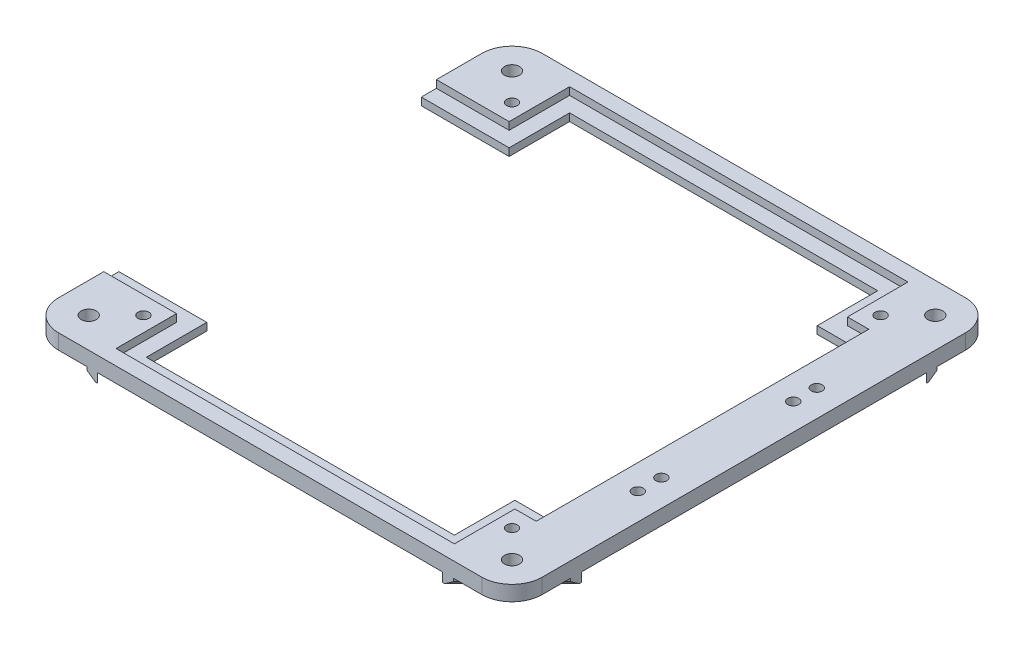
from build123d import *

# Parameters (mm, degrees)
BOSS_EXTRUDE2_DEPTH = 6.35
SKETCH2_R           = 3.175
CUT_EXTRUDE1_DEPTH  = 7.35
SKETCH7_R           = 2.286
CUT_EXTRUDE3_DEPTH  = 12.7
SKETCH8_R           = 2.286
CUT_EXTRUDE4_DEPTH  = 7.35
SKETCH9_W           = 129.404437756
SKETCH9_H           = 25.4
CUT_EXTRUDE5_DEPTH  = 7.35
CUT_EXTRUDE6_DEPTH  = 3.175
BOSS_EXTRUDE3_DEPTH = 3.81
CHAMFER1_SIZE       = 2.54


with BuildPart() as part:
    # Sketch1 → Boss-Extrude2 (new body)
    with BuildSketch(Plane(origin=(0, 0, 0), x_dir=(1, 0, 0), z_dir=(0, 1, 0))):
        with BuildLine():
            Line((0, 0), (0, 25.4))
            ThreePointArc((0, 25.4), (3.719743879, 34.380256121), (12.7, 38.1))
            Line((12.7, 38.1), (190.5, 38.1))
            ThreePointArc((190.5, 38.1), (199.480256121, 34.380256121), (203.2, 25.4))
            Line((203.2, 25.4), (203.2, -152.4))
            ThreePointArc((203.2, -152.4), (199.480256121, -161.380256121), (190.5, -165.1))
            Line((190.5, -165.1), (12.7, -165.1))
            ThreePointArc((12.7, -165.1), (3.719743879, -161.380256121), (0, -152.4))
            Line((0, -152.4), (0, -127))
            Line((0, -127), (181.61, -127))
            Line((181.61, -127), (181.61, 0))
            Line((181.61, 0), (0, 0))
        make_face()
    extrude(amount=BOSS_EXTRUDE2_DEPTH)

    # Sketch2 → Cut-Extrude1 (cut, through all)
    with BuildSketch(Plane(origin=(0, 6.35, 0), x_dir=(1, 0, 0), z_dir=(0, 1, 0))):
        with Locations((12.7, 25.4)):
            Circle(SKETCH2_R)
        with Locations((190.5, 25.4)):
            Circle(SKETCH2_R)
        with Locations((190.5, -152.4)):
            Circle(SKETCH2_R)
        with Locations((12.7, -152.4)):
            Circle(SKETCH2_R)
    extrude(amount=-CUT_EXTRUDE1_DEPTH, mode=Mode.SUBTRACT)

    # Sketch7 → Cut-Extrude3 (cut)
    with BuildSketch(Plane(origin=(0, 6.35, 0), x_dir=(1, 0, 0), z_dir=(0, 1, 0))):
        with Locations((192.024, -101.092)):
            Circle(SKETCH7_R)
        with Locations((192.024, -91.186)):
            Circle(SKETCH7_R)
        with Locations((192.024, -35.814)):
            Circle(SKETCH7_R)
        with Locations((192.024, -25.908)):
            Circle(SKETCH7_R)
    extrude(amount=-CUT_EXTRUDE3_DEPTH, mode=Mode.SUBTRACT)

    # Sketch8 → Cut-Extrude4 (cut, through all)
    with BuildSketch(Plane(origin=(0, 0, 0), x_dir=(-1, 0, 0), z_dir=(0, -1, 0))):
        with Locations((-24.197781122, 13.902218878)):
            Circle(SKETCH8_R)
        with Locations((-24.197781122, -140.902218878)):
            Circle(SKETCH8_R)
        with Locations((-179.002218878, -140.902218878)):
            Circle(SKETCH8_R)
        with Locations((-179.002218878, 13.902218878)):
            Circle(SKETCH8_R)
    extrude(amount=-CUT_EXTRUDE4_DEPTH, mode=Mode.SUBTRACT)

    # Sketch9 → Cut-Extrude5 (cut, through all)
    with BuildSketch(Plane(origin=(0, 6.35, 0), x_dir=(1, 0, 0), z_dir=(0, 1, 0))):
        with Locations((101.6, 12.7)):
            Rectangle(SKETCH9_W, SKETCH9_H)
        with Locations((101.6, -139.7)):
            Rectangle(SKETCH9_W, SKETCH9_H)
    extrude(amount=-CUT_EXTRUDE5_DEPTH, mode=Mode.SUBTRACT)

    # Sketch10 → Cut-Extrude6 (cut)
    with BuildSketch(Plane(origin=(0, 6.35, 0), x_dir=(1, 0, 0), z_dir=(0, 1, 0))):
        Polygon((0, 6.35), (30.547781122, 6.35), (30.547781122, 31.75), (172.652218878, 31.75), (172.652218878, 6.35), (181.61, 6.35), (181.61, 0), (166.302218878, 0), (166.302218878, 25.4), (36.897781122, 25.4), (36.897781122, 0), (0, 0), align=None)
        Polygon((0, -127), (0, -133.35), (30.547781122, -133.35), (30.547781122, -158.75), (172.652218878, -158.75), (172.652218878, -133.35), (181.61, -133.35), (181.61, -127), (166.302218878, -127), (166.302218878, -152.4), (36.897781122, -152.4), (36.897781122, -127), align=None)
    extrude(amount=-CUT_EXTRUDE6_DEPTH, mode=Mode.SUBTRACT)

    # Sketch11 → Boss-Extrude3 (add)
    with BuildSketch(Plane.XZ):
        with BuildLine():
            Line((174.07128, -38.1), (187.384850533, -24.786429467))
            ThreePointArc((187.384850533, -24.786429467), (187.552268433, -26.579620112), (188.668154157, -27.993253903))
            Line((188.668154157, -27.993253903), (178.561408061, -38.1))
            Line((178.561408061, -38.1), (174.07128, -38.1))
        make_face()
        with BuildLine():
            Line((203.2, -8.97128), (203.2, -13.461408061))
            Line((203.2, -13.461408061), (193.093253903, -23.568154157))
            ThreePointArc((193.093253903, -23.568154157), (191.679620112, -22.452268433), (189.886429467, -22.284850533))
            Line((189.886429467, -22.284850533), (203.2, -8.97128))
        make_face()
        with BuildLine():
            Line((10.106746097, -23.568154157), (0, -13.461408061))
            Line((0, -13.461408061), (0, -8.97128))
            Line((0, -8.97128), (13.313570533, -22.284850533))
            ThreePointArc((13.313570533, -22.284850533), (11.520379888, -22.452268433), (10.106746097, -23.568154157))
        make_face()
        with BuildLine():
            Line((15.815149467, -24.786429467), (29.12872, -38.1))
            Line((29.12872, -38.1), (24.638591939, -38.1))
            Line((24.638591939, -38.1), (14.531845843, -27.993253903))
            ThreePointArc((14.531845843, -27.993253903), (15.647731567, -26.579620112), (15.815149467, -24.786429467))
        make_face()
        with BuildLine():
            Line((14.531845843, 154.993253903), (24.638591939, 165.1))
            Line((24.638591939, 165.1), (29.12872, 165.1))
            Line((29.12872, 165.1), (15.815149467, 151.786429467))
            ThreePointArc((15.815149467, 151.786429467), (15.647731567, 153.579620112), (14.531845843, 154.993253903))
        make_face()
        with BuildLine():
            Line((13.313570533, 149.284850533), (0, 135.97128))
            Line((0, 135.97128), (0, 140.461408061))
            Line((0, 140.461408061), (10.106746097, 150.568154157))
            ThreePointArc((10.106746097, 150.568154157), (11.520379888, 149.452268433), (13.313570533, 149.284850533))
        make_face()
        with BuildLine():
            Line((193.093253903, 150.568154157), (203.2, 140.461408061))
            Line((203.2, 140.461408061), (203.2, 135.97128))
            Line((203.2, 135.97128), (189.886429467, 149.284850533))
            ThreePointArc((189.886429467, 149.284850533), (191.679620112, 149.452268433), (193.093253903, 150.568154157))
        make_face()
        with BuildLine():
            Line((187.384850533, 151.786429467), (174.07128, 165.1))
            Line((174.07128, 165.1), (178.561408061, 165.1))
            Line((178.561408061, 165.1), (188.668154157, 154.993253903))
            ThreePointArc((188.668154157, 154.993253903), (187.552268433, 153.579620112), (187.384850533, 151.786429467))
        make_face()
    extrude(amount=BOSS_EXTRUDE3_DEPTH)

    # Chamfer1
    chamfer1_edges = [part.edges().sort_by_distance(p)[0] for p in [
        (183.614781109, -3.81, -33.046626952),
        (198.146626952, -3.81, -18.514781109),
        (5.053373048, -3.81, -18.514781109),
        (19.585218891, -3.81, -33.046626952),
        (19.585218891, -3.81, 160.046626952),
        (5.053373048, -3.81, 145.514781109),
        (198.146626952, -3.81, 145.514781109),
        (183.614781109, -3.81, 160.046626952),
    ]]
    chamfer(chamfer1_edges, length=CHAMFER1_SIZE)


solid = part.part
